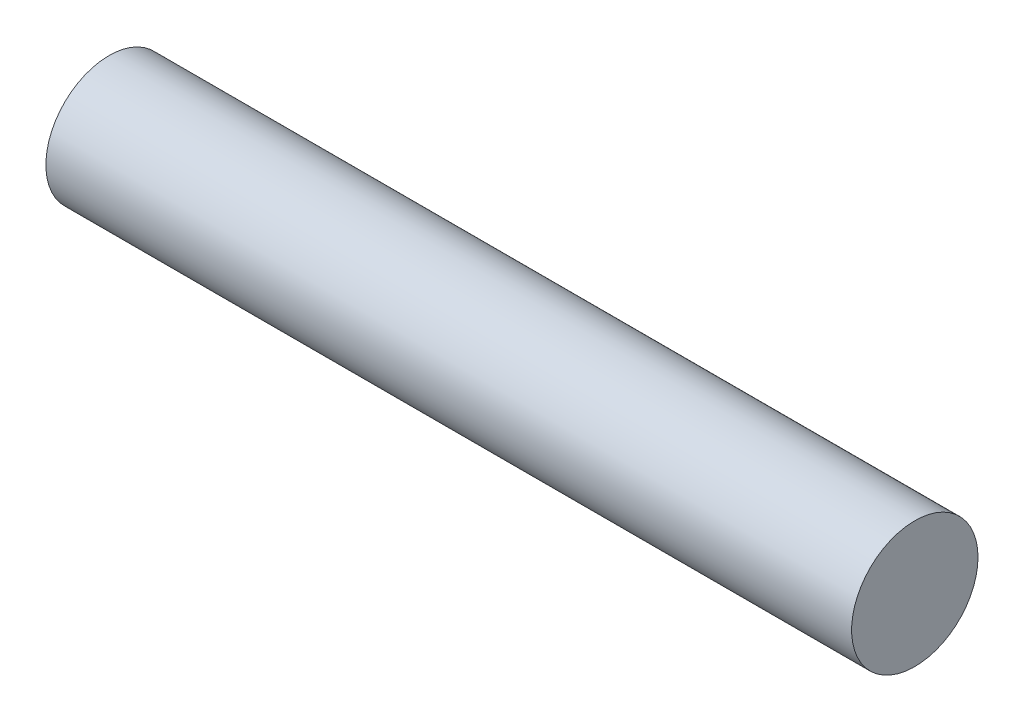
from build123d import *

# Parameters (mm, degrees)
SKETCH1_R           = 6.35
BOSS_EXTRUDE1_DEPTH = 80.9625


with BuildPart() as part:
    # Sketch1 → Boss-Extrude1 (new body)
    with BuildSketch(Plane(origin=(0, 0, 0), x_dir=(0, 0, -1), z_dir=(1, 0, 0))):
        Circle(SKETCH1_R)
    extrude(amount=BOSS_EXTRUDE1_DEPTH)


solid = part.part
